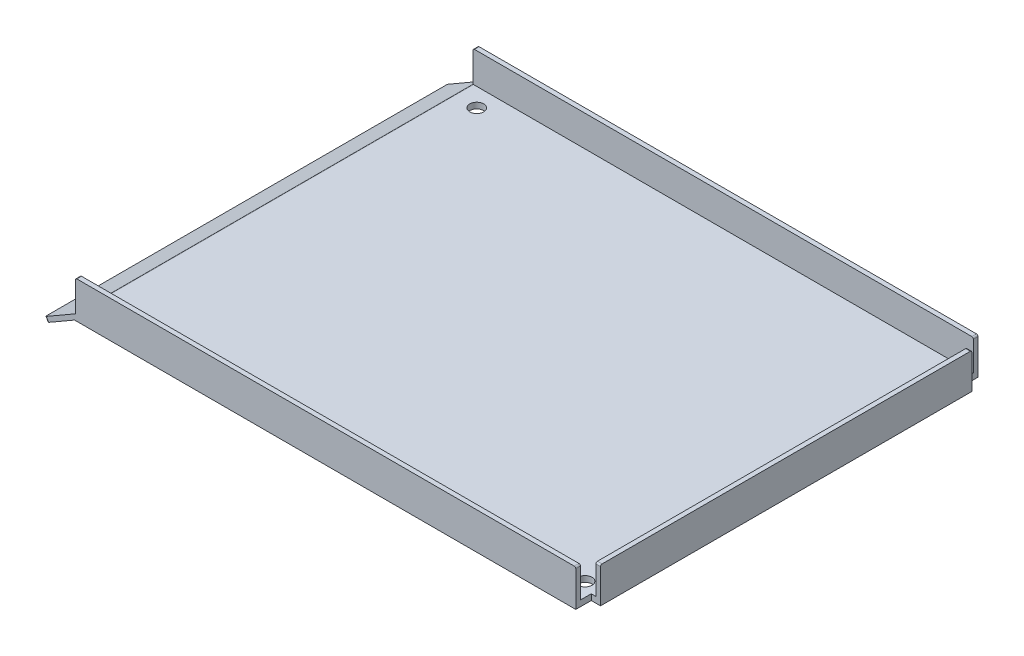
from build123d import *

# Parameters (mm, degrees)
BOSS_EXTRUDE1_DEPTH = 130
SKETCH3_W           = 3
SKETCH3_H           = 5
CUT_EXTRUDE1_DEPTH  = 12.5
SKETCH4_W           = 161.719208284
SKETCH4_H           = 1.5
BOSS_EXTRUDE2_DEPTH = 10
SKETCH5_R           = 2.25
CUT_EXTRUDE2_DEPTH  = 7.945980836
FILLET1_R           = 0.5


with BuildPart() as part:
    # Sketch1 → Boss-Extrude1 (new body)
    with BuildSketch(Plane.XY):
        Polygon((-4.857650715, 2.326869046), (-14.638442431, -3.320073684), (-13.888442431, -4.61911179), (-5.138442431, 0.432703066), (159.861557569, 0.432703066), (159.861557569, 11.932703066), (158.361557569, 11.932703066), (158.361557569, 2.326869046), align=None)
    extrude(amount=BOSS_EXTRUDE1_DEPTH)

    # Sketch3 → Cut-Extrude1 (cut, through all)
    with BuildSketch(Plane.XZ.offset(-0.432703066)):
        with Locations((158.361557569, 127.5)):
            Rectangle(SKETCH3_W, SKETCH3_H)
        with Locations((158.361557569, 2.5)):
            Rectangle(SKETCH3_W, SKETCH3_H)
    extrude(amount=-CUT_EXTRUDE1_DEPTH, mode=Mode.SUBTRACT)

    # Sketch4 → Boss-Extrude2 (add)
    with BuildSketch(Plane(origin=(0, 2.326869046, 0), x_dir=(1, 0, 0), z_dir=(0, 1, 0))):
        with Locations((76.001953427, -129.25)):
            Rectangle(SKETCH4_W, SKETCH4_H)
        with Locations((76.001953427, -0.75)):
            Rectangle(SKETCH4_W, SKETCH4_H)
    extrude(amount=BOSS_EXTRUDE2_DEPTH)

    # Sketch5 → Cut-Extrude2 (cut, through all)
    with BuildSketch(Plane(origin=(0, 2.326869046, 0), x_dir=(1, 0, 0), z_dir=(0, 1, 0))):
        with Locations((2.361557569, -122.5)):
            Circle(SKETCH5_R)
        with Locations((2.361557569, -7.5)):
            Circle(SKETCH5_R)
        with Locations((152.361557569, -7.5)):
            Circle(SKETCH5_R)
        with Locations((152.361557569, -122.5)):
            Circle(SKETCH5_R)
    extrude(amount=-CUT_EXTRUDE2_DEPTH, mode=Mode.SUBTRACT)

    # Fillet1
    fillet1_edges = [part.edges().sort_by_distance(p)[0] for p in [
        (-14.263442431, -3.969592737, 130),
        (159.111557569, 11.932703066, 125),
        (159.111557569, 11.932703066, 5),
        (-4.857650715, 2.326869046, 65),
        (156.861557569, 12.326869046, 129.25),
        (-4.857650715, 12.326869046, 129.25),
        (-4.857650715, 12.326869046, 0.75),
        (156.861557569, 12.326869046, 0.75),
        (-14.263442431, -3.969592737, 0),
    ]]
    fillet(fillet1_edges, radius=FILLET1_R)


solid = part.part
